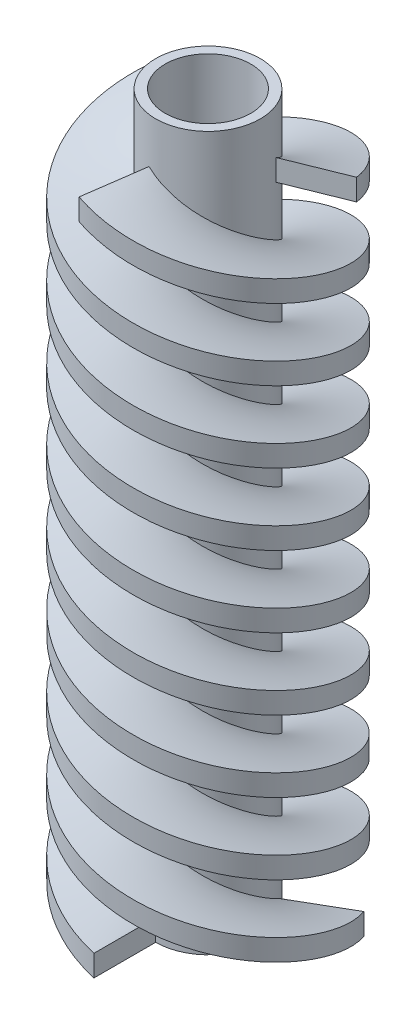
from build123d import *
from build123d.topology import SkipClean

# Parameters (mm, degrees)
SKIZZE1_R                       = 11
SKIZZE1_R_2                     = 9
AUFSATZ_LINEAR_AUSTRAGEN1_DEPTH = 150
AUSTRAGUNG1_PITCH               = 45
AUSTRAGUNG1_HEIGHT              = 136
AUSTRAGUNG1_RADIUS              = 11
SKIZZE3_W                       = 13
SKIZZE3_H                       = 4.5
KREISMUSTER1_COUNT              = 3


with BuildPart() as part:
    # Skizze1 → Aufsatz-Linear austragen1 (new body)
    with BuildSketch(Plane(origin=(0, 0, 0), x_dir=(1, 0, 0), z_dir=(0, 1, 0))):
        with Locations(Location((0, 0, 0), (0, 0, 270))):  # turned: the seam where the file's is
            Circle(SKIZZE1_R)
        with Locations(Location((0, 0, 0), (0, 0, 270))):  # turned: the seam where the file's is
            Circle(SKIZZE1_R_2, mode=Mode.SUBTRACT)
    extrude(amount=AUFSATZ_LINEAR_AUSTRAGEN1_DEPTH)

    # Austragung1: sweep along a helix
    with BuildLine() as austragung1_path:
        Helix(AUSTRAGUNG1_PITCH, AUSTRAGUNG1_HEIGHT, AUSTRAGUNG1_RADIUS, center=(0, 0, 0), direction=(0, 1, 0), lefthand=True)
    # Skizze3 → Austragung1 (sweep)
    with BuildSketch(Plane(origin=(0, 0, 0), x_dir=(0, 0, -1), z_dir=(1, 0, 0))):
        with Locations((-17.5, 2.25)):
            Rectangle(SKIZZE3_W, SKIZZE3_H)
    austragung1 = sweep(path=austragung1_path.line, is_frenet=True)

    # Kreismuster1: Austragung1 ×3 about axis
    with SkipClean():  # keep this step's faces unmerged: merging them makes the solid invalid here
        kreismuster1_axis = Axis((0, 150, 0), (0, -1, 0))
        for i in range(1, KREISMUSTER1_COUNT):
            add(austragung1.rotate(kreismuster1_axis, i * 360 / KREISMUSTER1_COUNT))


solid = part.part
